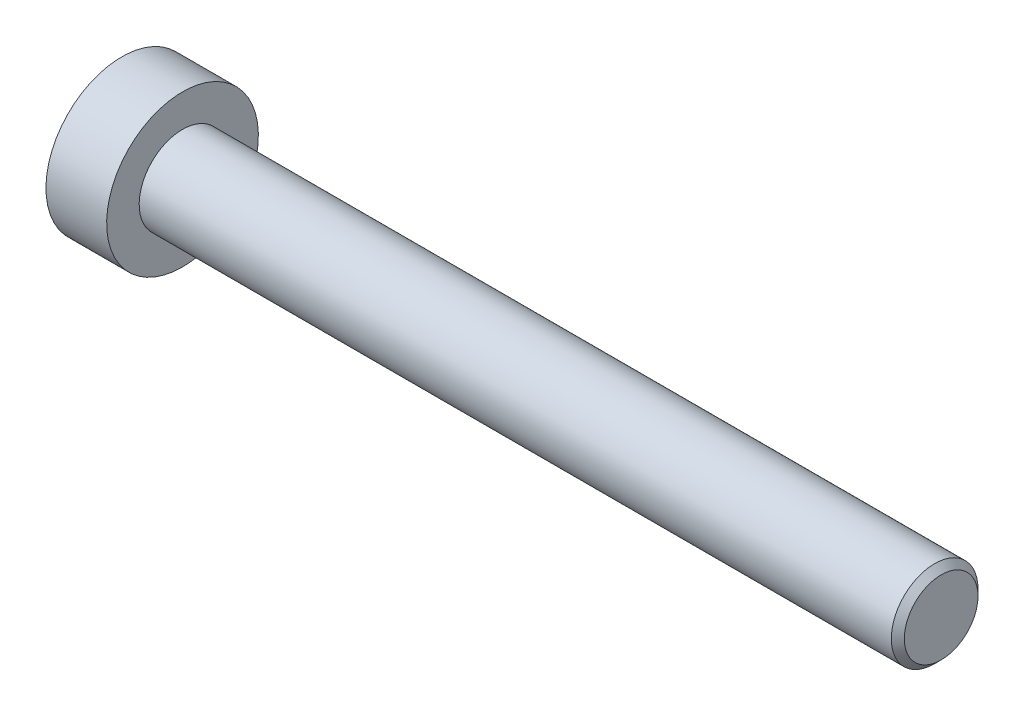
from build123d import *

# Parameters (mm, degrees)
SKETCH2_R           = 2
BOSS_EXTRUDE1_DEPTH = 35
CHAMFER1_SIZE       = 0.3
SKETCH6_W           = 2.8
SKETCH6_H           = 3.5
CUT_EXTRUDE1_DEPTH  = 1.6
SKETCH8_R           = 1.493375673
CUT_EXTRUDE2_DEPTH  = 1
CUT_EXTRUDE2_TAPER  = 45


with BuildPart() as part:
    # Sketch2 → Boss-Extrude1 (new body)
    with BuildSketch(Plane(origin=(0, 0, 0), x_dir=(0, 0, -1), z_dir=(1, 0, 0))):
        Circle(SKETCH2_R)
    extrude(amount=-BOSS_EXTRUDE1_DEPTH)

    # Chamfer1
    chamfer1_edges = [part.edges().sort_by_distance(p)[0] for p in [
        (0, 0, 2),
    ]]
    chamfer(chamfer1_edges, length=CHAMFER1_SIZE)

    # Sketch6 → Revolve1 (revolve)
    with BuildSketch(Plane.XY):
        with Locations((-36.4, 1.75)):
            Rectangle(SKETCH6_W, SKETCH6_H)
    revolve(axis=Axis((-35, 0, 0), (1, 0, 0)))

    # Sketch7 → Cut-Extrude1 (cut)
    with BuildSketch(Plane.ZY.offset(37.8)):
        Polygon((0, 1.443375673), (-1.25, 0.721687836), (-1.25, -0.721687836), (0, -1.443375673), (1.25, -0.721687836), (1.25, 0.721687836), align=None)
    extrude(amount=-CUT_EXTRUDE1_DEPTH, mode=Mode.SUBTRACT)

    # Sketch8 → Cut-Extrude2 (cut)
    with BuildSketch(Plane.ZY.offset(37.8)):
        Circle(SKETCH8_R)
    extrude(amount=-CUT_EXTRUDE2_DEPTH, taper=CUT_EXTRUDE2_TAPER, mode=Mode.SUBTRACT)


solid = part.part
